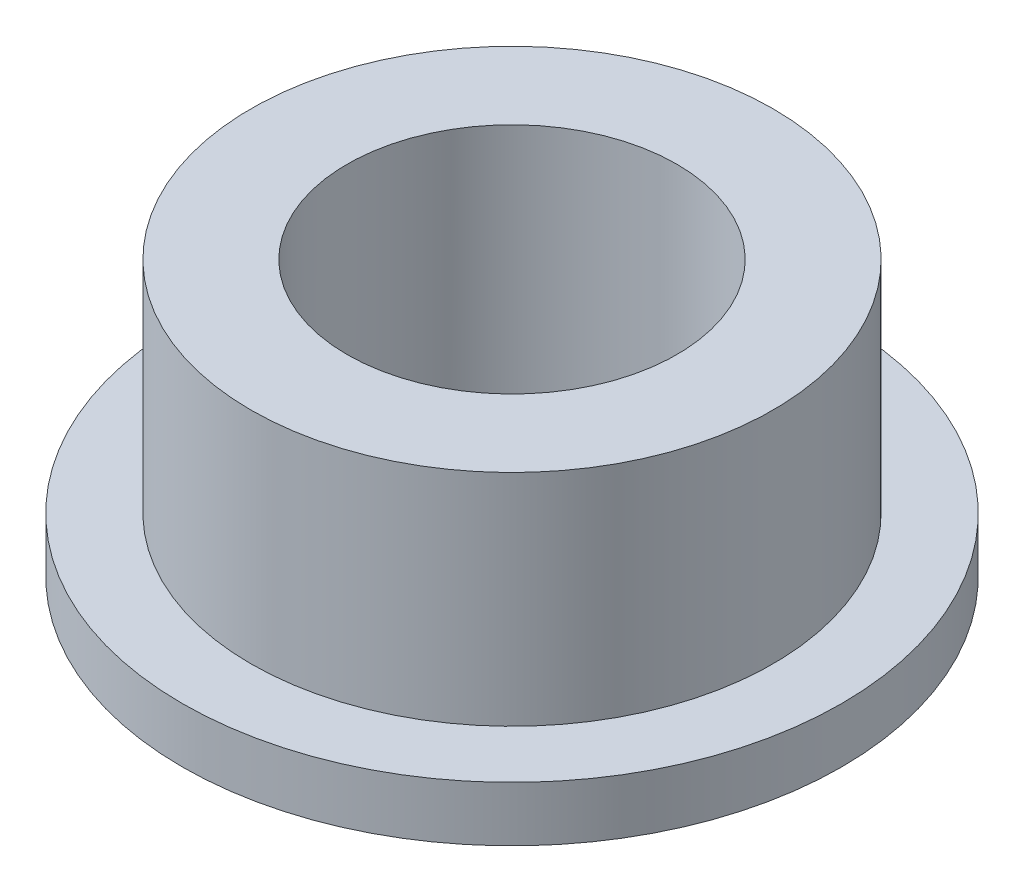
from build123d import *

# Parameters (mm, degrees)
SKETCH1_R           = 4.75
SKETCH1_R_2         = 3.001
BOSS_EXTRUDE1_DEPTH = 4
SKETCH2_R           = 6
SKETCH2_R_2         = 3.001
BOSS_EXTRUDE2_DEPTH = 1
SCALE1_SCALE        = 1.5


with BuildPart() as part:
    # Sketch1 → Boss-Extrude1 (new body)
    with BuildSketch(Plane(origin=(0, 0, 0), x_dir=(1, 0, 0), z_dir=(0, 1, 0))):
        Circle(SKETCH1_R)
        Circle(SKETCH1_R_2, mode=Mode.SUBTRACT)
    extrude(amount=BOSS_EXTRUDE1_DEPTH)

    # Sketch2 → Boss-Extrude2 (add)
    with BuildSketch(Plane.XZ):
        Circle(SKETCH2_R)
        Circle(SKETCH2_R_2, mode=Mode.SUBTRACT)
    extrude(amount=BOSS_EXTRUDE2_DEPTH)


with BuildPart() as part_1:
    # Scale1: scaled about (0, 1.169108574, 0)
    add(part.part.scale(SCALE1_SCALE).moved(Location((0, -0.584554287, 0))))


solid = part_1.part
